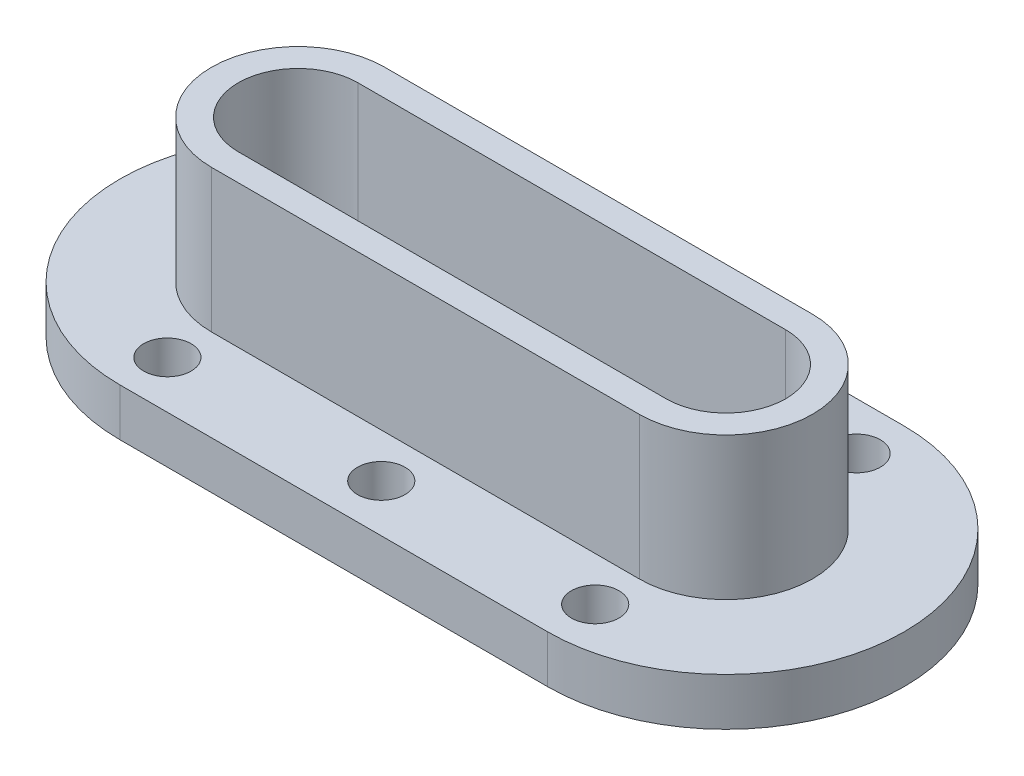
from build123d import *

# Parameters (mm, degrees)
BOSS_EXTRUDE1_DEPTH = 20
SKETCH2_R           = 10
CUT_EXTRUDE1_DEPTH  = 20
LPATTERN1_COUNT     = 3
LPATTERN1_PITCH     = 90
SKETCH4_R           = 10
CUT_EXTRUDE2_DEPTH  = 20
LPATTERN2_COUNT     = 3
LPATTERN2_PITCH     = 90
SKETCH5_R           = 7.5
CUT_EXTRUDE4_DEPTH  = 20
LPATTERN4_COUNT     = 3
LPATTERN4_PITCH     = 90
BOSS_EXTRUDE3_DEPTH = 60


with BuildPart() as part:
    # Sketch1 → Boss-Extrude1 (new body)
    with BuildSketch(Plane(origin=(0, 0, 0), x_dir=(1, 0, 0), z_dir=(0, 1, 0))):
        with BuildLine():
            Line((-90, -75), (90, -75))
            ThreePointArc((90, -75), (165, 0), (90, 75))
            Line((90, 75), (-90, 75))
            ThreePointArc((-90, 75), (-165, 0), (-90, -75))
        make_face()
    extrude(amount=BOSS_EXTRUDE1_DEPTH)

    # Sketch2 → Cut-Extrude1 (cut)
    with BuildSketch(Plane(origin=(0, 20, 0), x_dir=(1, 0, 0), z_dir=(0, 1, 0))):
        with Locations((-90, 55)):
            Circle(SKETCH2_R)
    cut_extrude1 = extrude(amount=-CUT_EXTRUDE1_DEPTH, mode=Mode.SUBTRACT)

    # LPattern1: Cut-Extrude1 ×3
    with Locations(*[(i * LPATTERN1_PITCH, 0, 0) for i in range(1, LPATTERN1_COUNT)]):
        add(cut_extrude1, mode=Mode.SUBTRACT)

    # Sketch4 → Cut-Extrude2 (cut)
    with BuildSketch(Plane(origin=(0, 20, 0), x_dir=(1, 0, 0), z_dir=(0, 1, 0))):
        with Locations((-90, -55)):
            Circle(SKETCH4_R)
    cut_extrude2 = extrude(amount=-CUT_EXTRUDE2_DEPTH, mode=Mode.SUBTRACT)

    # LPattern2: Cut-Extrude2 ×3
    with Locations(*[(i * LPATTERN2_PITCH, 0, 0) for i in range(1, LPATTERN2_COUNT)]):
        add(cut_extrude2, mode=Mode.SUBTRACT)

    # Sketch5 → Cut-Extrude4 (cut)
    with BuildSketch(Plane(origin=(0, 20, 0), x_dir=(1, 0, 0), z_dir=(0, 1, 0))):
        with Locations((-90, 0)):
            Circle(SKETCH5_R)
    cut_extrude4 = extrude(amount=-CUT_EXTRUDE4_DEPTH, mode=Mode.SUBTRACT)

    # LPattern4: Cut-Extrude4 ×3
    with Locations(*[(i * LPATTERN4_PITCH, 0, 0) for i in range(1, LPATTERN4_COUNT)]):
        add(cut_extrude4, mode=Mode.SUBTRACT)

    # Sketch6 → Boss-Extrude3 (add)
    with BuildSketch(Plane(origin=(0, 20, 0), x_dir=(1, 0, 0), z_dir=(0, 1, 0))):
        with BuildLine():
            Line((-90, 36.456417916), (90, 36.456417916))
            ThreePointArc((90, 36.456417916), (126.456417916, 0), (90, -36.456417916))
            Line((90, -36.456417916), (-90, -36.456417916))
            ThreePointArc((-90, -36.456417916), (-126.456417916, 0), (-90, 36.456417916))
        make_face()
        with BuildLine():
            Line((-90, 25.16029231), (90, 25.16029231))
            ThreePointArc((90, 25.16029231), (115.16029231, 0), (90, -25.16029231))
            Line((90, -25.16029231), (-90, -25.16029231))
            ThreePointArc((-90, -25.16029231), (-115.16029231, 0), (-90, 25.16029231))
        make_face(mode=Mode.SUBTRACT)
    extrude(amount=BOSS_EXTRUDE3_DEPTH)


solid = part.part
